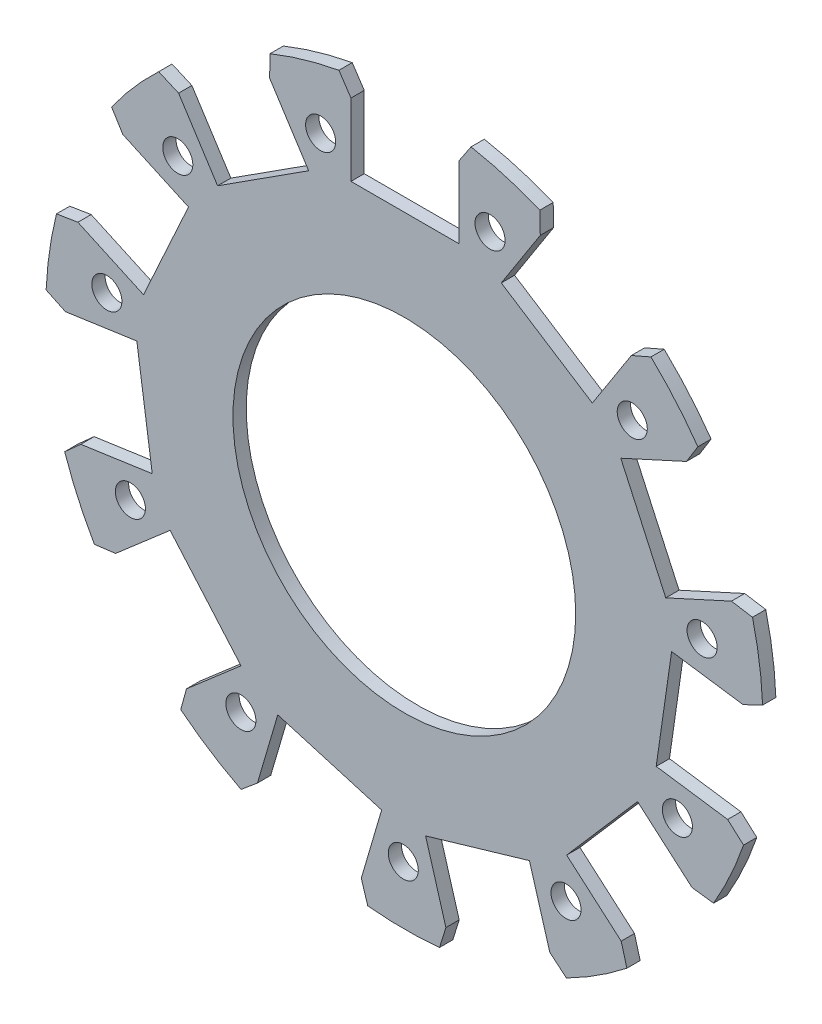
from build123d import *

# Parameters (mm, degrees)
SKETCH1_R           = 59.625
SKETCH1_R_2         = 28.5
BOSS_EXTRUDE1_DEPTH = 2.21
CUT_EXTRUDE2_DEPTH  = 2.21
SKETCH6_R           = 2.5
CUT_EXTRUDE4_DEPTH  = 2.21


with BuildPart() as part:
    # Sketch1 → Boss-Extrude1 (new body)
    with BuildSketch(Plane.XY):
        Circle(SKETCH1_R)
        Circle(SKETCH1_R_2, mode=Mode.SUBTRACT)
    extrude(amount=BOSS_EXTRUDE1_DEPTH)

    # Sketch2 → Cut-Extrude2 (cut)
    with BuildSketch(Plane.XY.offset(2.21)):
        Polygon((-8.874281585, 55.625), (-10.874281585, 58.625), (-8.874281585, 59.625), (9.125718415, 59.625), (11.125718415, 58.625), (9.125718415, 55.625), (9.125718415, 43.625), (-8.874281585, 43.625), align=None)
        Polygon((22.607624736, 51.592526614), (22.547040123, 55.197568848), (24.770188006, 54.957540746), (39.912751597, 45.226006032), (41.054617845, 43.303470864), (37.750188327, 41.8609919), (31.262498517, 31.765949506), (16.119934926, 41.49748422), align=None)
        Polygon((46.911769941, 31.179790564), (48.809835901, 34.245299594), (50.550297923, 32.841450616), (58.027768157, 16.4680747), (57.948966187, 14.233395696), (54.389240175, 14.806414648), (43.473656231, 9.821434492), (35.996185997, 26.194810408), align=None)
        Polygon((56.321759653, 0.867691316), (59.575853655, 2.420389685), (60.281045421, 0.298431963), (57.719378332, -17.518353991), (56.444927213, -19.355682037), (53.760092564, -16.949094638), (41.882235262, -15.241316579), (44.443902351, 2.575469375), align=None)
        Polygon((47.849988626, -29.719893795), (51.426958817, -30.172976848), (50.872986923, -32.339336731), (39.085493712, -45.942829069), (37.02002267, -46.799467484), (36.062495415, -43.323386133), (26.993500522, -35.465057326), (38.780993734, -21.861564987), align=None)
        Polygon((24.186184301, -50.871622616), (26.950367919, -53.186636423), (25.313114529, -54.709594511), (8.042241004, -59.780780534), (5.8415225, -59.384752674), (6.915310776, -55.942808639), (3.534520094, -44.428892956), (20.805393619, -39.357706933), align=None)
        Polygon((-7.156562647, -55.871970699), (-6.08277437, -59.313914733), (-8.283492875, -59.709942593), (-25.5543664, -54.63875657), (-27.19161979, -53.115798483), (-24.427436172, -50.800784675), (-21.04664549, -39.286868992), (-3.775771965, -44.358055015), align=None)
        Polygon((-36.227151521, -43.133362857), (-37.184678776, -46.609444207), (-39.250149819, -45.752805792), (-51.03764303, -32.149313454), (-51.591614923, -29.982953571), (-48.014644732, -29.529870518), (-38.94564984, -21.671541711), (-27.158156629, -35.275034049), align=None)
        Polygon((-53.795875756, -16.700217074), (-56.480710405, -19.106804472), (-57.755161524, -17.269476427), (-60.316828612, 0.547309527), (-59.611636847, 2.669267249), (-56.357542845, 1.11656888), (-44.479685542, 2.82434694), (-41.918018453, -14.992439014), align=None)
        Polygon((-54.284789542, 15.035129632), (-57.844515554, 14.462110681), (-57.923317523, 16.696789684), (-50.445847289, 33.070165601), (-48.705385268, 34.474014578), (-46.807319308, 31.408505549), (-35.891735364, 26.423525393), (-43.369205598, 10.050149476), align=None)
        Polygon((-37.538666206, 41.996928913), (-40.843095724, 43.439407877), (-39.701229476, 45.361943044), (-24.558665885, 55.093477759), (-22.335518002, 55.333505861), (-22.396102615, 51.728463627), (-15.908412806, 41.633421233), (-31.050976397, 31.901886519), align=None)
    extrude(amount=-CUT_EXTRUDE2_DEPTH, mode=Mode.SUBTRACT)

    # Sketch6 → Cut-Extrude4 (cut)
    with BuildSketch(Plane.XY.offset(2.21)):
        with Locations((-13.918677225, 48.02364443)):
            Circle(SKETCH6_R)
        with Locations((14.254405994, 47.925065569)):
            Circle(SKETCH6_R)
        with Locations((37.901816027, 32.610617012)):
            Circle(SKETCH6_R)
        with Locations((49.515667272, 6.942527969)):
            Circle(SKETCH6_R)
        with Locations((45.40864402, -20.92976465)):
            Circle(SKETCH6_R)
        with Locations((26.884697133, -42.157004875)):
            Circle(SKETCH6_R)
        with Locations((-0.174951135, -49.99969392)):
            Circle(SKETCH6_R)
        with Locations((-27.179053654, -41.967833426)):
            Circle(SKETCH6_R)
        with Locations((-45.553998676, -20.61148235)):
            Circle(SKETCH6_R)
        with Locations((-49.465870987, 7.288868739)):
            Circle(SKETCH6_R)
        with Locations((-37.672678769, 32.875055503)):
            Circle(SKETCH6_R)
    extrude(amount=-CUT_EXTRUDE4_DEPTH, mode=Mode.SUBTRACT)


solid = part.part
